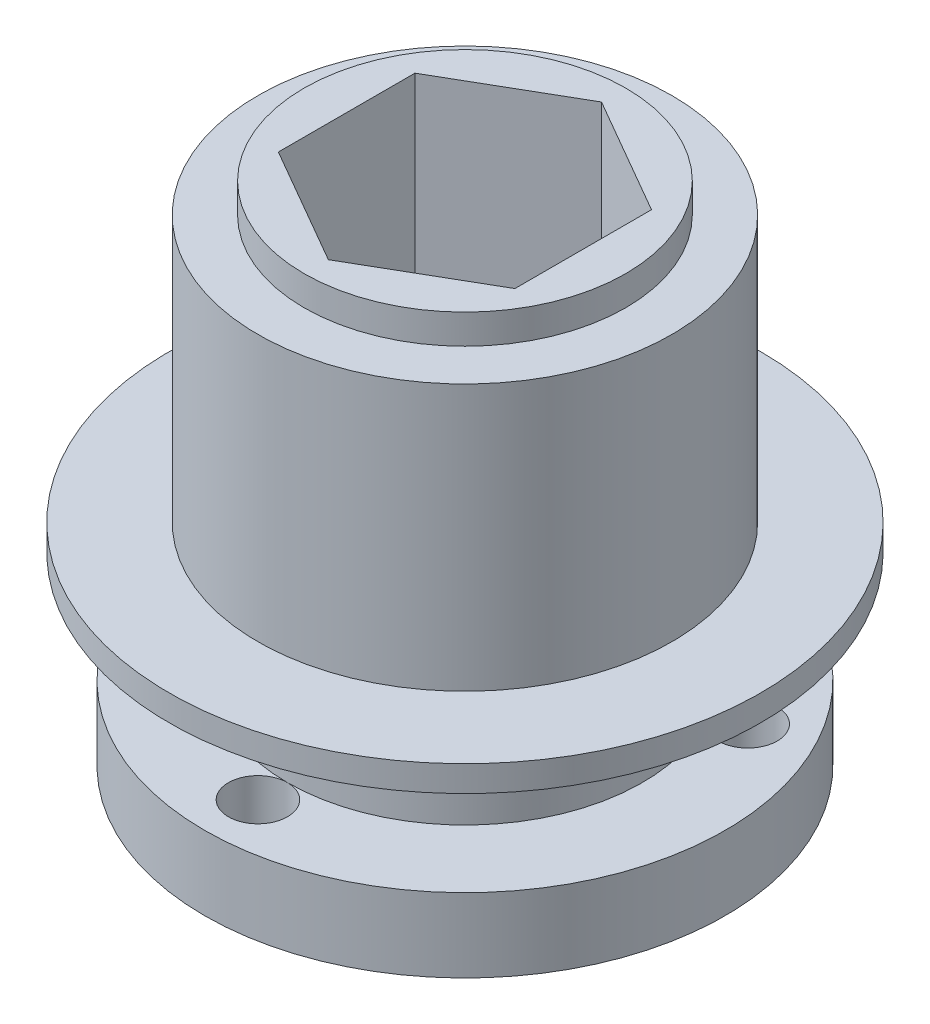
from build123d import *

# Parameters (mm, degrees)
CUT_EXTRUDE1_DEPTH = 101.6
SKETCH3_R          = 3.175
CUT_EXTRUDE2_DEPTH = 12.7


with BuildPart() as part:
    # Sketch1 → Revolve1 (revolve)
    with BuildSketch(Plane.XY):
        Polygon((0, 0), (27.94, 0), (27.94, 7.9375), (19.05, 7.9375), (19.05, 19.84375), (31.75, 19.84375), (31.75, 22.621875), (22.225, 22.621875), (22.225, 51.196875), (17.2640625, 51.196875), (17.2640625, 54.371875), (0, 54.371875), align=None)
    revolve(axis=Axis((0, 0, 0), (0, 1, 0)))

    # Sketch2 → Cut-Extrude1 (cut)
    with BuildSketch(Plane.XZ):
        Polygon((12.7, 7.332348419), (0, 14.664696837), (-12.7, 7.332348419), (-12.7, -7.332348419), (0, -14.664696837), (12.7, -7.332348419), align=None)
    extrude(amount=-CUT_EXTRUDE1_DEPTH, mode=Mode.SUBTRACT)

    # Sketch3 → Cut-Extrude2 (cut)
    with BuildSketch(Plane.XZ):
        with Locations((0, 22.225)):
            Circle(SKETCH3_R)
        with Locations((19.247414599, -11.1125)):
            Circle(SKETCH3_R)
        with Locations((-19.247414599, -11.1125)):
            Circle(SKETCH3_R)
    extrude(amount=-CUT_EXTRUDE2_DEPTH, mode=Mode.SUBTRACT)


solid = part.part
